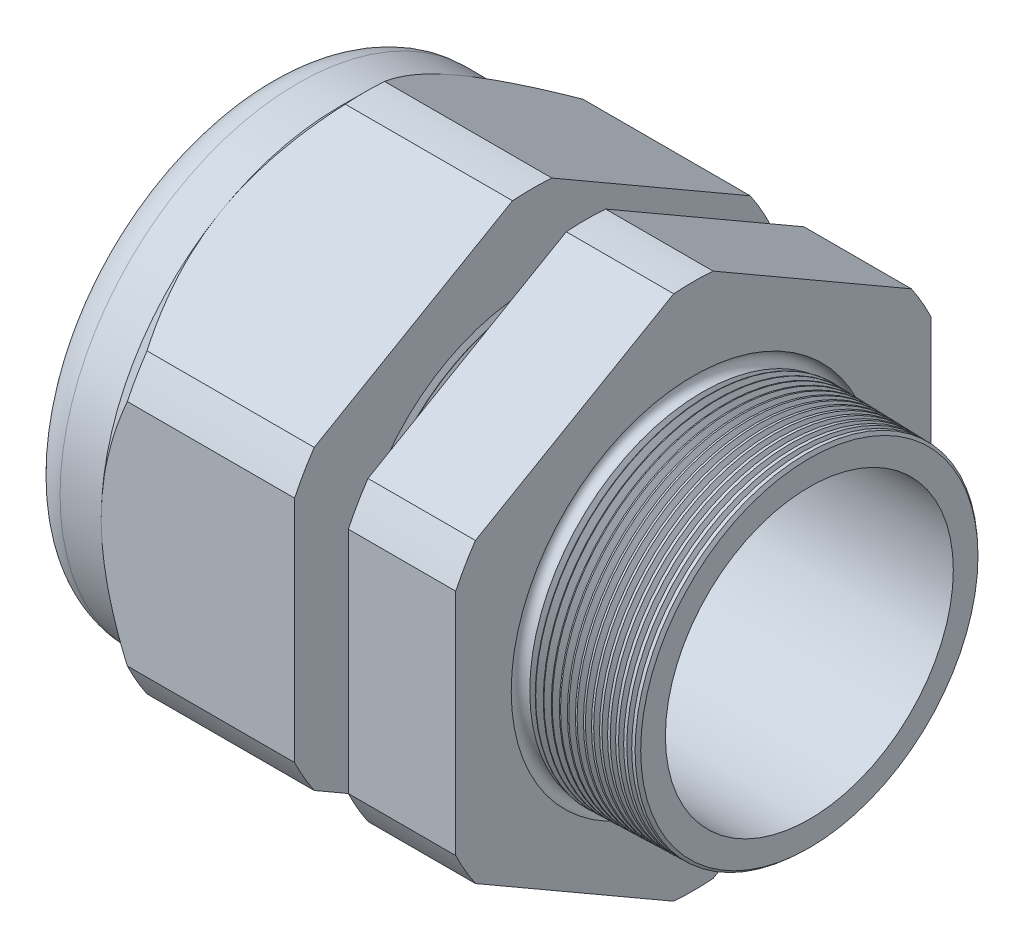
from build123d import *

# Parameters (mm, degrees)
SKETCH12_OUTSIDE_W = 140.582
SKETCH12_OUTSIDE_H = 140.582
CUT_EXTRUDE2_DEPTH = 53.5600168
FILLET4_R          = 3.81
SKETCH19_OUTSIDE_W = 83.088
SKETCH19_OUTSIDE_H = 88.928
SKETCH19_OUTSIDE_R = 26.543
CUT_EXTRUDE3_DEPTH = 3.99796
CUT_EXTRUDE3_DRAFT = -45
CHAMFER1_SIZE      = 0.260919487
CHAMFER1_SIZE2     = 0.254
SKETCH21_R         = 16.002
PLUG_DEPTH         = 12.7
SKETCH22_R         = 15.748
CUT_EXTRUDE4_DEPTH = 0.508
LPATTERN1_COUNT    = 8
LPATTERN1_PITCH    = 0.762
LPATTERN2_COUNT    = 15
LPATTERN2_PITCH    = 0.889
SKETCH32_R         = 0.889


with BuildPart() as part:
    # Sketch10 → Revolve2 (revolve)
    with BuildSketch(Plane.XY, mode=Mode.PRIVATE) as revolve2_sk:
        Polygon((-55.88, 16.002), (-25.87759112, 16.002), (5.08, 16.080346947), (5.08, 19.128346947), (-7.874, 19.467559375), (-7.874, 53.086), (-19.873976, 53.086), (-19.873976, 19.781789805), (-25.87759112, 19.939), (-25.87759112, 53.086), (-47.4800168, 53.086), (-47.4800168, 26.543), (-55.88, 26.543), align=None)
    revolve(revolve2_sk.sketch.rotate(Axis((0, 0, 0), (-1, 0, 0)), 90), axis=Axis((0, 0, 0), (-1, 0, 0)))  # turned: the seam where the file's is

    # Sketch12 outside → Cut-Extrude2 (cut, through all)
    with BuildSketch(Plane.ZY.offset(47.4800168)):
        Rectangle(SKETCH12_OUTSIDE_W, SKETCH12_OUTSIDE_H)
        with BuildLine():
            Line((-2.19715092, 29.380690715), (-24.34584908, 16.59313387))
            ThreePointArc((-24.34584908, 16.59313387), (-25.515472645, 14.731365), (-26.543, 12.787556845))
            Line((-26.543, 12.787556845), (-26.543, -12.787556845))
            ThreePointArc((-26.543, -12.787556845), (-25.515472645, -14.731365), (-24.34584908, -16.59313387))
            Line((-24.34584908, -16.59313387), (-2.19715092, -29.380690715))
            ThreePointArc((-2.19715092, -29.380690715), (0, -29.46273), (2.19715092, -29.380690715))
            Line((2.19715092, -29.380690715), (24.34584908, -16.59313387))
            ThreePointArc((24.34584908, -16.59313387), (25.515472645, -14.731365), (26.543, -12.787556845))
            Line((26.543, -12.787556845), (26.543, 12.787556845))
            ThreePointArc((26.543, 12.787556845), (25.515472645, 14.731365), (24.34584908, 16.59313387))
            Line((24.34584908, 16.59313387), (2.19715092, 29.380690715))
            ThreePointArc((2.19715092, 29.380690715), (0, 29.46273), (-2.19715092, 29.380690715))
        make_face(mode=Mode.SUBTRACT)
    extrude(amount=-CUT_EXTRUDE2_DEPTH, mode=Mode.SUBTRACT)

    # Fillet4
    fillet4_edges = [part.edges().sort_by_distance(p)[0] for p in [
        (-55.88, 0, 26.543),
    ]]
    fillet(fillet4_edges, radius=FILLET4_R)


with BuildPart() as cut_extrude3_tool:
    # Sketch19 outside → Cut-Extrude3 (with draft: the straight prism first)
    with BuildSketch(Plane.ZY.offset(47.4800168)):
        Rectangle(SKETCH19_OUTSIDE_W, SKETCH19_OUTSIDE_H)
        Circle(SKETCH19_OUTSIDE_R, mode=Mode.SUBTRACT)
    extrude(amount=-CUT_EXTRUDE3_DEPTH)
    # Cut-Extrude3: the draft: its side faces are tilted about the plane it starts from
    cut_extrude3_sides = [cut_extrude3_tool.faces().sort_by_distance(p)[0] for p in [
        (-45.4810368, -44.464, 0),
        (-45.4810368, 0, 41.544),
        (-45.4810368, 44.464, 0),
        (-45.4810368, 0, -41.544),
        (-45.4810368, 0, -26.543),
    ]]
    draft(cut_extrude3_sides, Plane.ZY.offset(47.4800168), CUT_EXTRUDE3_DRAFT)


with BuildPart() as part_1:
    add(part.part)

    # Cut-Extrude3: cut by cut_extrude3_tool
    add(cut_extrude3_tool.part, mode=Mode.SUBTRACT)

    # Chamfer1
    chamfer1_edges = [part_1.edges().sort_by_distance(p)[0] for p in [
        (5.08, 0, 19.128346947),
    ]]
    chamfer1_side = [part_1.faces().sort_by_distance(p)[0] for p in [
        (5.08, 0, 16.621378301),
    ]]
    chamfer(chamfer1_edges, length=CHAMFER1_SIZE, length2=CHAMFER1_SIZE2, reference=chamfer1_side[0])

    # Sketch29 → Cut-Revolve1 (revolve, cut)
    with BuildSketch(Plane.XY, mode=Mode.PRIVATE) as cut_revolve1_sk:
        Polygon((-25.87759112, 19.939), (-25.144607539, 19.919806149), (-25.527721692, 19.294620673), align=None)
    cut_revolve1 = revolve(cut_revolve1_sk.sketch.rotate(Axis((0, 0, 0), (-1, 0, 0)), 90), axis=Axis((0, 0, 0), (-1, 0, 0)), mode=Mode.SUBTRACT)  # turned: the seam where the file's is

    # LPattern1: Cut-Revolve1 ×8
    with Locations(*[(i * LPATTERN1_PITCH, 0, 0) for i in range(1, LPATTERN1_COUNT)]):
        add(cut_revolve1, mode=Mode.SUBTRACT)

    # Sketch30 → Cut-Revolve2 (revolve, cut)
    with BuildSketch(Plane.XY, mode=Mode.PRIVATE) as cut_revolve2_sk:
        Polygon((-7.874, 19.467559375), (-6.994419703, 19.444526754), (-7.454156686, 18.694304183), align=None)
    cut_revolve2 = revolve(cut_revolve2_sk.sketch.rotate(Axis((0, 0, 0), (-1, 0, 0)), 270), axis=Axis((0, 0, 0), (-1, 0, 0)), mode=Mode.SUBTRACT)  # turned: the seam where the file's is

    # LPattern2: Cut-Revolve2 ×15
    with Locations(*[(i * LPATTERN2_PITCH, 0, 0) for i in range(1, LPATTERN2_COUNT)]):
        add(cut_revolve2, mode=Mode.SUBTRACT)

    # Sketch32 → Cut-Revolve3 (revolve, cut)
    with BuildSketch(Plane.XY, mode=Mode.PRIVATE) as cut_revolve3_sk:
        with Locations((-7.747, 19.467559375)):
            Circle(SKETCH32_R)
    revolve(cut_revolve3_sk.sketch.rotate(Axis((0, 0, 0), (-1, 0, 0)), 270), axis=Axis((0, 0, 0), (-1, 0, 0)), mode=Mode.SUBTRACT)  # turned: the seam where the file's is


with BuildPart() as body_2:
    # Sketch21 → plug (new body)
    with BuildSketch(Plane.ZY.offset(55.88)):
        Circle(SKETCH21_R)
    extrude(amount=-PLUG_DEPTH)

    # Sketch22 → Cut-Extrude4 (cut)
    with BuildSketch(Plane.ZY.offset(55.88)):
        Circle(SKETCH22_R)
    extrude(amount=-CUT_EXTRUDE4_DEPTH, mode=Mode.SUBTRACT)


solid = Compound([part_1.part, body_2.part])
